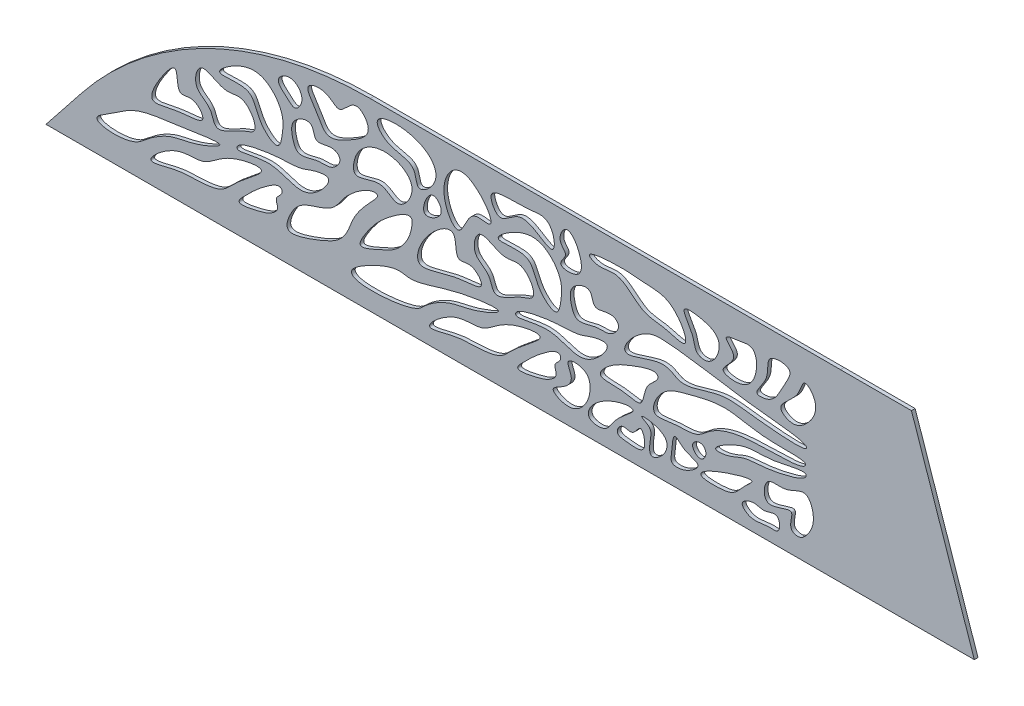
from build123d import *

# Parameters (mm, degrees)
SALIENTE_EXTRUIR1_DEPTH = 1


with BuildPart() as part:
    # Croquis2 → Saliente-Extruir1 (new body)
    with BuildSketch(Plane.XY):
        with BuildLine():
            Line((-140.923407086, 16.513809916), (-150.634750193, 4.281119486))
            Line((-150.634750193, 4.281119486), (81.974483808, 4.428260628))
            Line((81.974483808, 4.428260628), (101.237882269, 4.428260628))
            Line((101.237882269, 4.428260628), (84.179871787, 54.417480281))
            Line((84.179871787, 54.417480281), (64.916473326, 54.417480281))
            Line((64.916473326, 54.417480281), (-62.66668653, 54.336775265))
            ThreePointArc((-62.66668653, 54.336775265), (-106.11925474, 44.37219373), (-140.923407086, 16.513809916))
        make_face()
        with BuildLine():
            add(Edge.make_bspline(
                [(-92.205684954, 22.714796973), (-91.802560007, 21.763045235), (-98.804615112, 17.236326929), (-102.576737947, 12.23957137), (-109.402464372, 11.501499563), (-114.719362778, 11.744524185), (-125.825393726, 8.076123538), (-115.369854681, 17.42010162), (-107.474200982, 15.63632551), (-102.30806793, 21.870076839), (-92.605251322, 23.658147136), (-92.205684954, 22.714796973)],
                knots=[0, 0, 0, 0, 0.137666911, 0.216152979, 0.304696955, 0.407966614, 0.504225833, 0.632893463, 0.744250149, 0.863548342, 1, 1, 1, 1], degree=3))
        make_face(mode=Mode.SUBTRACT)
        with BuildLine():
            add(Edge.make_bspline(
                [(-86.575132814, 20.597298305), (-86.453176706, 19.69679669), (-89.367071096, 18.116368228), (-86.916603685, 16.0539287), (-89.862651004, 13.618513225), (-93.383907232, 12.534630146), (-100.071587714, 11.196574042), (-96.060944144, 15.052423007), (-92.78317285, 18.380734009), (-87.196303675, 22.305241626), (-86.595495362, 20.747651644), (-86.575132814, 20.597298305)],
                knots=[0, 0, 0, 0, 0.100037862, 0.223752743, 0.272835489, 0.361931863, 0.526926229, 0.683101427, 0.832970576, 0.983297058, 1, 1, 1, 1], degree=3))
        make_face(mode=Mode.SUBTRACT)
        with BuildLine():
            add(Edge.make_bspline(
                [(-27.875451607, 21.716419118), (-28.042422713, 21.083876098), (-35.12534219, 18.025053036), (-41.178852373, 17.621695169), (-47.389772208, 13.857790251), (-51.023345798, 9.288841508), (-76.678379325, 7.823413857), (-56.039840283, 18.687568859), (-51.166789821, 16.20059075), (-41.858487953, 20.802798425), (-27.643210348, 22.59622756), (-27.875451607, 21.716419118)],
                knots=[0, 0, 0, 0, 0.101306786, 0.208687695, 0.319856438, 0.369897245, 0.539759423, 0.585965852, 0.671453306, 0.859091694, 1, 1, 1, 1], degree=3))
        make_face(mode=Mode.SUBTRACT)
        with BuildLine():
            add(Edge.make_bspline(
                [(-16.609741445, 21.420728237), (-16.206616498, 20.468976499), (-23.208671604, 15.942258194), (-26.980794438, 10.945502634), (-33.806520863, 10.207430828), (-39.123419269, 10.450455449), (-50.229450217, 6.782054803), (-39.773911172, 16.126032885), (-31.878257474, 14.342256774), (-26.712124421, 20.576008103), (-17.009307813, 22.364078401), (-16.609741445, 21.420728237)],
                knots=[0, 0, 0, 0, 0.137666911, 0.216152979, 0.304696955, 0.407966614, 0.504225833, 0.632893463, 0.744250149, 0.863548342, 1, 1, 1, 1], degree=3))
        make_face(mode=Mode.SUBTRACT)
        with BuildLine():
            add(Edge.make_bspline(
                [(-103.471395116, 23.010487854), (-103.619901272, 22.446352179), (-110.695490352, 19.291825157), (-116.904148272, 18.901199105), (-122.596194499, 15.222899499), (-127.782380381, 10.368532406), (-140.636545521, 11.269519032), (-132.414774866, 15.857270722), (-126.152722763, 20.727532604), (-117.607238327, 21.261724361), (-103.264836882, 23.795148047), (-103.471395116, 23.010487854)],
                knots=[0, 0, 0, 0, 0.101306786, 0.208687695, 0.319856438, 0.369897245, 0.539759423, 0.585965852, 0.671453306, 0.859091694, 1, 1, 1, 1], degree=3))
        make_face(mode=Mode.SUBTRACT)
        with BuildLine():
            add(Edge.make_bspline(
                [(-60.73742357, 32.564353965), (-60.271937474, 31.593304482), (-66.076211875, 27.724556688), (-69.421439661, 17.825803591), (-73.680771059, 15.183714533), (-78.0102017, 13.515587852), (-86.67036516, 10.47225481), (-83.67595972, 18.408432631), (-80.577836796, 20.914590464), (-72.859550638, 22.732736455), (-68.574252013, 29.726559886), (-62.405794108, 33.536573592), (-60.804454521, 32.70418708), (-60.73742357, 32.564353965)],
                knots=[0, 0, 0, 0, 0.139538346, 0.165887445, 0.263490987, 0.357787779, 0.488799598, 0.565750137, 0.69720214, 0.788875945, 0.819155731, 0.979906192, 1, 1, 1, 1], degree=3))
        make_face(mode=Mode.SUBTRACT)
        with BuildLine():
            add(Edge.make_bspline(
                [(-98.758161385, 24.574610579), (-98.277956099, 23.630831376), (-87.811743674, 27.779195859), (-80.679689336, 19.962886758), (-71.966189082, 30.620756207), (-77.8972006, 29.960216513), (-81.651012757, 28.066728549), (-88.115487595, 28.353175745), (-98.709877292, 26.471512653), (-98.822584456, 24.701225499), (-98.758161385, 24.574610579)],
                knots=[0, 0, 0, 0, 0.173914473, 0.388452632, 0.503873436, 0.557098589, 0.647485373, 0.766680945, 0.976668095, 1, 1, 1, 1], degree=3))
        make_face(mode=Mode.SUBTRACT)
        with BuildLine():
            add(Edge.make_bspline(
                [(-51.329656744, 30.329113167), (-51.684364022, 27.088103468), (-54.454716076, 22.541795298), (-60.039369763, 20.094348809), (-67.090616873, 17.017062152), (-62.46106287, 24.396988676), (-58.822981991, 28.413339103), (-51.078469767, 33.712617249), (-51.296448609, 30.632540507), (-51.329656744, 30.329113167)],
                knots=[0, 0, 0, 0, 0.224720507, 0.375822377, 0.501740602, 0.617102565, 0.78961388, 0.978961388, 1, 1, 1, 1], degree=3))
        make_face(mode=Mode.SUBTRACT)
        with BuildLine():
            add(Edge.make_bspline(
                [(-32.477538359, 25.779047969), (-32.436786797, 24.296704773), (-41.089243269, 24.706077459), (-51.339051208, 19.257750479), (-48.554505392, 29.983166486), (-38.574241423, 37.641213819), (-39.89615189, 27.378304205), (-34.921286445, 29.653255806), (-32.50396138, 26.740188673), (-32.477538359, 25.779047969)],
                knots=[0, 0, 0, 0, 0.14020184, 0.385455427, 0.525796143, 0.730510289, 0.839207685, 0.909094132, 1, 1, 1, 1], degree=3))
        make_face(mode=Mode.SUBTRACT)
        with BuildLine():
            add(Edge.make_bspline(
                [(-3.033262147, 8.916712976), (-2.244692201, 8.203526295), (1.470040688, 7.835400725), (3.530798908, 12.102338745), (6.127780455, 14.114768646), (10.814473459, 18.155324741), (-0.509412981, 16.233538463), (-4.348285226, 10.106026553), (-3.033262147, 8.916712976)],
                knots=[0, 0, 0, 0, 0.13121694, 0.261967856, 0.433385636, 0.495907082, 0.781181993, 1, 1, 1, 1], degree=3))
        make_face(mode=Mode.SUBTRACT)
        with BuildLine():
            add(Edge.make_bspline(
                [(-10.979189305, 19.303229569), (-10.857233197, 18.402727954), (-13.771127587, 16.822299492), (-11.320660177, 14.759859964), (-14.266707495, 12.32444449), (-17.787963723, 11.24056141), (-24.475644205, 9.902505306), (-20.465000635, 13.758354272), (-17.187229342, 17.086665274), (-11.600360166, 21.011172891), (-10.999551854, 19.453582908), (-10.979189305, 19.303229569)],
                knots=[0, 0, 0, 0, 0.100037862, 0.223752743, 0.272835489, 0.361931863, 0.526926229, 0.683101427, 0.832970576, 0.983297058, 1, 1, 1, 1], degree=3))
        make_face(mode=Mode.SUBTRACT)
        with BuildLine():
            add(Edge.make_bspline(
                [(-13.020020123, 10.844042343), (-13.079741619, 10.067018611), (-8.925268124, 7.980384497), (-4.615199834, 10.361871707), (-2.640858856, 14.932384707), (-3.353597744, 20.208995054), (-10.496104983, 20.404822533), (-7.165671724, 15.74557424), (-9.692856103, 12.772498346), (-12.968673963, 11.512096368), (-13.020020123, 10.844042343)],
                knots=[0, 0, 0, 0, 0.115790929, 0.261605928, 0.423709519, 0.543191472, 0.682024284, 0.775824877, 0.900447576, 1, 1, 1, 1], degree=3))
        make_face(mode=Mode.SUBTRACT)
        with BuildLine():
            add(Edge.make_bspline(
                [(5.589406647, 11.457118018), (4.864473397, 11.147060302), (3.518627666, 8.767568714), (7.91915639, 8.388545505), (12.909094615, 7.716484892), (10.920139502, 15.515485139), (8.713691841, 10.317718328), (6.493094754, 11.843630115), (5.589406647, 11.457118018)],
                knots=[0, 0, 0, 0, 0.11702101, 0.265473491, 0.499789655, 0.707726475, 0.854123817, 1, 1, 1, 1], degree=3))
        make_face(mode=Mode.SUBTRACT)
        with BuildLine():
            add(Edge.make_bspline(
                [(11.068959568, 16.296260232), (11.345693545, 16.022397332), (14.108483371, 14.901540724), (13.108457293, 11.919706032), (12.994442149, 7.52081155), (17.528521559, 10.165795766), (19.258710949, 16.206665104), (10.349245704, 17.008507164), (11.068959568, 16.296260232)],
                knots=[0, 0, 0, 0, 0.100831532, 0.25515108, 0.381411636, 0.512576107, 0.737763133, 1, 1, 1, 1], degree=3))
        make_face(mode=Mode.SUBTRACT)
        with BuildLine():
            add(Edge.make_bspline(
                [(20.029504698, 16.296260232), (19.396010342, 16.196927939), (19.300073517, 12.808771346), (18.449298601, 8.960869803), (23.36795948, 9.302114629), (28.012613549, 13.316849909), (22.599537026, 13.70507933), (20.542918285, 16.376763788), (20.029504698, 16.296260232)],
                knots=[0, 0, 0, 0, 0.174988013, 0.298355592, 0.478987194, 0.673221019, 0.858181494, 1, 1, 1, 1], degree=3))
        make_face(mode=Mode.SUBTRACT)
        with BuildLine():
            add(Edge.make_bspline(
                [(29.24000352, 12.743992104), (25.975683225, 11.089660736), (26.09550318, 9.83401953), (33.75643826, 10.225014229), (36.673456582, 11.054678144), (38.337312262, 13.685479114), (43.159155366, 17.68986783), (33.442795047, 14.637836975), (30.031739731, 13.145237671), (29.24000352, 12.743992104)],
                knots=[0, 0, 0, 0, 0.381237911, 0.430835157, 0.495972459, 0.63184877, 0.681407126, 0.907533627, 1, 1, 1, 1], degree=3))
        make_face(mode=Mode.SUBTRACT)
        with BuildLine():
            add(Edge.make_bspline(
                [(24.824599415, 16.833368405), (24.607789074, 15.798700476), (26.848267052, 13.414357491), (28.899100312, 16.204061152), (27.486935928, 18.898146726), (25.020559407, 17.768533754), (24.824599415, 16.833368405)],
                knots=[0, 0, 0, 0, 0.304007816, 0.526233533, 0.725228194, 1, 1, 1, 1], degree=3))
        make_face(mode=Mode.SUBTRACT)
        with BuildLine():
            add(Edge.make_bspline(
                [(47.738883242, 11.340551354), (48.62260712, 10.685832918), (48.713093751, 7.472736449), (44.227586396, 8.08967099), (40.993801578, 6.374792092), (37.257188326, 10.015279646), (41.456913555, 11.994955727), (44.190662415, 10.304045855), (46.943426943, 11.929875597), (47.738883242, 11.340551354)],
                knots=[0, 0, 0, 0, 0.160267158, 0.21076581, 0.504986522, 0.580130515, 0.727204348, 0.85574055, 1, 1, 1, 1], degree=3))
        make_face(mode=Mode.SUBTRACT)
        with BuildLine():
            add(Edge.make_bspline(
                [(45.054720682, 18.081996856), (46.06927865, 19.190478678), (50.34468551, 17.737364414), (55.852853916, 22.53607311), (58.251146001, 15.543939157), (56.605204987, 11.765461856), (54.086303424, 8.999676875), (50.449404652, 10.195663467), (53.688210171, 17.037464328), (43.649269803, 10.259098879), (44.058719335, 16.993789556), (45.054720682, 18.081996856)],
                knots=[0, 0, 0, 0, 0.115773361, 0.264232273, 0.386481489, 0.502340138, 0.579489949, 0.628580772, 0.723680545, 0.886344174, 1, 1, 1, 1], degree=3))
        make_face(mode=Mode.SUBTRACT)
        with BuildLine():
            add(Edge.make_bspline(
                [(-23.162217877, 23.280541843), (-22.68201259, 22.33676264), (-12.215800165, 26.485127123), (-5.083745828, 18.668818023), (3.629754427, 29.326687471), (-2.301257091, 28.666147777), (-6.055069248, 26.772659814), (-12.519544086, 27.059107009), (-23.113933783, 25.177443917), (-23.226640947, 23.407156764), (-23.162217877, 23.280541843)],
                knots=[0, 0, 0, 0, 0.173914473, 0.388452632, 0.503873436, 0.557098589, 0.647485373, 0.766680945, 0.976668095, 1, 1, 1, 1], degree=3))
        make_face(mode=Mode.SUBTRACT)
        with BuildLine():
            add(Edge.make_bspline(
                [(15.381956031, 27.714692848), (15.253882238, 26.713156926), (11.358376869, 24.683201722), (11.696956364, 19.060483861), (8.464003922, 19.248459826), (4.856118523, 20.204669131), (-2.257724891, 19.489916631), (2.256785883, 24.388350028), (7.049215017, 26.680027692), (15.167352982, 29.580336225), (15.403340027, 27.881915502), (15.381956031, 27.714692848)],
                knots=[0, 0, 0, 0, 0.100037862, 0.223752743, 0.272835489, 0.361931863, 0.526926229, 0.683101427, 0.832970576, 0.983297058, 1, 1, 1, 1], degree=3))
        make_face(mode=Mode.SUBTRACT)
        with BuildLine():
            add(Edge.make_bspline(
                [(55.488285601, 27.436087963), (55.30394795, 28.433925607), (42.760617862, 27.52349654), (34.27751659, 30.758631897), (24.11490803, 28.112824625), (15.861942033, 26.002779475), (12.735310907, 17.684288379), (20.543013488, 19.522878334), (25.75479227, 18.798442261), (30.066503999, 23.125621961), (39.12867169, 26.619479492), (54.241877688, 25.199437951), (55.519153324, 27.268997975), (55.488285601, 27.436087963)],
                knots=[0, 0, 0, 0, 0.114550047, 0.246019978, 0.351313901, 0.440260507, 0.519920021, 0.570512894, 0.6558102, 0.704961009, 0.808183564, 0.980818356, 1, 1, 1, 1], degree=3))
        make_face(mode=Mode.SUBTRACT)
        with BuildLine():
            add(Edge.make_bspline(
                [(55.571158094, 25.062930246), (55.054545663, 25.987282937), (44.178039045, 22.629287652), (39.35475209, 24.787397273), (28.873846675, 18.30981476), (34.988684692, 18.759787933), (38.58860678, 20.957324311), (45.108017123, 20.822637604), (55.550092321, 23.261880754), (55.640465451, 24.938921535), (55.571158094, 25.062930246)],
                knots=[0, 0, 0, 0, 0.173914473, 0.388452632, 0.503873436, 0.557098589, 0.647485373, 0.766680945, 0.976668095, 1, 1, 1, 1], degree=3))
        make_face(mode=Mode.SUBTRACT)
        with BuildLine():
            add(Edge.make_bspline(
                [(-108.073481868, 27.073116705), (-108.041265106, 25.569592773), (-115.011431825, 25.865998801), (-123.856158818, 22.466065593), (-120.195936147, 30.313584003), (-114.453306123, 37.590138326), (-115.494295858, 28.517152828), (-110.518238625, 30.990858991), (-108.094370986, 28.047990845), (-108.073481868, 27.073116705)],
                knots=[0, 0, 0, 0, 0.16554106, 0.363113048, 0.54333429, 0.681804372, 0.810147069, 0.892664364, 1, 1, 1, 1], degree=3))
        make_face(mode=Mode.SUBTRACT)
        with BuildLine():
            add(Edge.make_bspline(
                [(-109.776725626, 33.714538143), (-109.103916475, 32.062460714), (-105.83207503, 31.203315351), (-104.745362123, 24.457077502), (-98.83128897, 29.39842089), (-92.206027167, 30.710204303), (-96.620153924, 38.328213681), (-102.598608626, 35.350248088), (-109.056212015, 41.337207318), (-110.399214891, 35.2430555), (-109.776725626, 33.714538143)],
                knots=[0, 0, 0, 0, 0.122947635, 0.197230717, 0.379613325, 0.462451253, 0.61342153, 0.720954251, 0.886247708, 1, 1, 1, 1], degree=3))
        make_face(mode=Mode.SUBTRACT)
        with BuildLine():
            add(Edge.make_bspline(
                [(-103.471395116, 40.06414663), (-102.922868116, 39.345851186), (-94.044466633, 41.43345587), (-93.815432944, 34.147991751), (-87.369341096, 28.986697114), (-86.39264908, 34.561309264), (-86.006961443, 39.198135198), (-90.398993123, 45.011314598), (-97.179996163, 45.713177477), (-104.03971449, 40.808360162), (-103.471395116, 40.06414663)],
                knots=[0, 0, 0, 0, 0.150869226, 0.29454511, 0.406379079, 0.468936505, 0.566427014, 0.712110948, 0.843686995, 1, 1, 1, 1], degree=3))
        make_face(mode=Mode.SUBTRACT)
        with BuildLine():
            add(Edge.make_bspline(
                [(-34.180782118, 32.420469407), (-33.507972967, 30.768391979), (-30.236131522, 29.909246615), (-29.149418615, 23.163008766), (-23.235345461, 28.104352154), (-16.610083659, 29.416135568), (-21.024210416, 37.034144946), (-27.002665117, 34.056179352), (-33.460268506, 40.043138582), (-34.803271383, 33.948986764), (-34.180782118, 32.420469407)],
                knots=[0, 0, 0, 0, 0.122947635, 0.197230717, 0.379613325, 0.462451253, 0.61342153, 0.720954251, 0.886247708, 1, 1, 1, 1], degree=3))
        make_face(mode=Mode.SUBTRACT)
        with BuildLine():
            add(Edge.make_bspline(
                [(-83.199355761, 38.836812684), (-84.170283329, 37.670045282), (-84.030375686, 35.181011402), (-82.377033768, 30.409363197), (-77.229863483, 33.149625464), (-73.021490047, 32.116380807), (-69.982124829, 35.742723936), (-73.216723178, 38.462577552), (-77.87023712, 35.48221866), (-78.079098906, 41.72241535), (-82.088498364, 40.171734302), (-83.199355761, 38.836812684)],
                knots=[0, 0, 0, 0, 0.118785798, 0.20372498, 0.369297926, 0.472854545, 0.583848702, 0.633218082, 0.781041846, 0.864094823, 1, 1, 1, 1], degree=3))
        make_face(mode=Mode.SUBTRACT)
        with BuildLine():
            add(Edge.make_bspline(
                [(-66.586453789, 38.836812684), (-67.222535469, 37.306332509), (-67.89082393, 32.076313413), (-59.841552865, 37.55515985), (-54.893378171, 31.182575162), (-49.387842715, 39.115434549), (-56.857883142, 45.443217149), (-64.702440628, 43.36994873), (-66.586453789, 38.836812684)],
                knots=[0, 0, 0, 0, 0.101141447, 0.28046914, 0.396201309, 0.560751813, 0.700428697, 1, 1, 1, 1], degree=3))
        make_face(mode=Mode.SUBTRACT)
        with BuildLine():
            add(Edge.make_bspline(
                [(-47.87195203, 37.35315559), (-47.375731904, 38.834505454), (-45.552690706, 41.492142324), (-41.547391927, 36.321494257), (-48.600010912, 33.050936588), (-48.224400719, 36.301001939), (-47.87195203, 37.35315559)],
                knots=[0, 0, 0, 0, 0.24865073, 0.481622394, 0.823391638, 1, 1, 1, 1], degree=3))
        make_face(mode=Mode.SUBTRACT)
        with BuildLine():
            add(Edge.make_bspline(
                [(-87.566498355, 46.385773526), (-87.813009041, 45.274050288), (-85.555717254, 43.595440663), (-83.021561008, 41.06034201), (-80.530072842, 44.42138596), (-81.970001714, 47.670090828), (-85.187093106, 48.853875471), (-87.380646042, 47.223937333), (-87.566498355, 46.385773526)],
                knots=[0, 0, 0, 0, 0.218720128, 0.339791489, 0.498378835, 0.685975107, 0.83509988, 1, 1, 1, 1], degree=3))
        make_face(mode=Mode.SUBTRACT)
        with BuildLine():
            add(Edge.make_bspline(
                [(-79.479460945, 48.7142402), (-80.008377433, 47.63555805), (-77.001116385, 44.122950565), (-74.703573543, 38.371126383), (-67.809674107, 41.932745381), (-61.065412917, 46.106433193), (-67.058351553, 52.927844534), (-70.761719622, 45.754553623), (-74.359845914, 50.529509468), (-78.936737861, 49.82107978), (-79.479460945, 48.7142402)],
                knots=[0, 0, 0, 0, 0.116134081, 0.234719327, 0.387508115, 0.559608153, 0.66669632, 0.795438918, 0.880834407, 1, 1, 1, 1], degree=3))
        make_face(mode=Mode.SUBTRACT)
        with BuildLine():
            add(Edge.make_bspline(
                [(-42.636896587, 41.89482139), (-42.322641621, 38.423145799), (-37.98064402, 31.442174809), (-36.140595503, 42.389350621), (-26.399632488, 39.038676716), (-37.608319281, 54.738365525), (-43.019820846, 46.125108727), (-42.636896587, 41.89482139)],
                knots=[0, 0, 0, 0, 0.1985725, 0.381466523, 0.477585842, 0.758036513, 1, 1, 1, 1], degree=3))
        make_face(mode=Mode.SUBTRACT)
        with BuildLine():
            add(Edge.make_bspline(
                [(-60.73742357, 49.411543737), (-60.544662358, 48.417716552), (-56.990233275, 44.639081597), (-50.374853842, 45.85413483), (-50.103758986, 38.073608254), (-42.414802891, 44.445987791), (-48.862162473, 52.97712714), (-61.25919074, 52.101640943), (-60.73742357, 49.411543737)],
                knots=[0, 0, 0, 0, 0.102406098, 0.299110243, 0.378625468, 0.507829762, 0.722806579, 1, 1, 1, 1], degree=3))
        make_face(mode=Mode.SUBTRACT)
        with BuildLine():
            add(Edge.make_bspline(
                [(-7.603412252, 37.542743949), (-8.57433982, 36.375976546), (-8.434432177, 33.886942667), (-6.781090259, 29.115294461), (-1.633919974, 31.855556729), (2.574453462, 30.822312071), (5.61381868, 34.4486552), (2.379220331, 37.168508816), (-2.274293611, 34.188149924), (-2.483155397, 40.428346614), (-6.492554855, 38.877665566), (-7.603412252, 37.542743949)],
                knots=[0, 0, 0, 0, 0.118785798, 0.20372498, 0.369297926, 0.472854545, 0.583848702, 0.633218082, 0.781041846, 0.864094823, 1, 1, 1, 1], degree=3))
        make_face(mode=Mode.SUBTRACT)
        with BuildLine():
            add(Edge.make_bspline(
                [(55.330594504, 31.951770156), (53.753942259, 32.892358649), (38.259279371, 33.897354101), (23.619571951, 37.126650261), (10.47543016, 37.628852817), (1.919935836, 25.995389595), (17.745708547, 33.25357759), (21.186602511, 27.864955136), (32.164799048, 33.227691472), (40.30951101, 31.511181344), (57.011995933, 30.201433415), (55.576378826, 31.805141813), (55.330594504, 31.951770156)],
                knots=[0, 0, 0, 0, 0.099677328, 0.267067778, 0.297767809, 0.406677629, 0.47274056, 0.561818037, 0.712100252, 0.844613011, 0.984461301, 1, 1, 1, 1], degree=3))
        make_face(mode=Mode.SUBTRACT)
        with BuildLine():
            add(Edge.make_bspline(
                [(-27.875451607, 38.770077894), (-27.326924607, 38.051782451), (-18.448523125, 40.139387135), (-18.219489435, 32.853923016), (-11.773397587, 27.692628378), (-10.796705572, 33.267240528), (-10.411017935, 37.904066462), (-14.803049614, 43.717245862), (-21.584052654, 44.419108742), (-28.443770981, 39.514291427), (-27.875451607, 38.770077894)],
                knots=[0, 0, 0, 0, 0.150869226, 0.29454511, 0.406379079, 0.468936505, 0.566427014, 0.712110948, 0.843686995, 1, 1, 1, 1], degree=3))
        make_face(mode=Mode.SUBTRACT)
        with BuildLine():
            add(Edge.make_bspline(
                [(48.901820289, 36.79519151), (47.815314018, 38.509698209), (53.710954161, 41.007663891), (54.73582542, 47.711904561), (59.737426124, 42.844096735), (56.693691564, 37.249012986), (52.102443188, 34.588323926), (49.329797514, 36.119843527), (48.901820289, 36.79519151)],
                knots=[0, 0, 0, 0, 0.267800279, 0.390798431, 0.490723643, 0.760932173, 0.894512878, 1, 1, 1, 1], degree=3))
        make_face(mode=Mode.SUBTRACT)
        with BuildLine():
            add(Edge.make_bspline(
                [(-29.802585568, 46.972842654), (-29.55567134, 45.959950477), (-27.156428287, 41.790841066), (-21.417183367, 50.860753193), (-11.154552652, 38.680944887), (-13.227115494, 50.705363197), (-23.553154117, 49.090514995), (-30.673341877, 50.544861404), (-29.802585568, 46.972842654)],
                knots=[0, 0, 0, 0, 0.085286671, 0.253990522, 0.484166523, 0.647648619, 0.699231967, 1, 1, 1, 1], degree=3))
        make_face(mode=Mode.SUBTRACT)
        with BuildLine():
            add(Edge.make_bspline(
                [(-10.979189305, 46.328041782), (-11.539908087, 47.649864932), (-9.362094939, 52.60162348), (-5.010184746, 45.924459106), (-5.270658131, 40.031760119), (-12.842115939, 40.590791935), (-8.586164818, 44.211918431), (-10.624155118, 45.49109388), (-10.979189305, 46.328041782)],
                knots=[0, 0, 0, 0, 0.162087623, 0.409403319, 0.604230089, 0.77400643, 0.897369859, 1, 1, 1, 1], degree=3))
        make_face(mode=Mode.SUBTRACT)
        with BuildLine():
            add(Edge.make_bspline(
                [(-2.926589796, 46.827177569), (-2.710032306, 46.653292066), (-0.342680309, 45.375704857), (5.318644037, 47.943171987), (10.593661882, 40.478171265), (16.837350415, 40.832545137), (25.252486804, 37.459881273), (19.738655417, 48.168218872), (11.672093455, 47.97999359), (6.579706689, 49.071517615), (-4.466713729, 48.063824824), (-2.926589796, 46.827177569)],
                knots=[0, 0, 0, 0, 0.018173889, 0.122894497, 0.279653893, 0.384629408, 0.472626168, 0.608786908, 0.726153064, 0.870750066, 1, 1, 1, 1], degree=3))
        make_face(mode=Mode.SUBTRACT)
        with BuildLine():
            add(Edge.make_bspline(
                [(22.580112723, 47.450285128), (22.014138538, 46.594076013), (25.370804443, 42.895953704), (25.321887293, 38.69252172), (30.36624504, 37.50233275), (33.749183526, 45.08648144), (28.010643168, 47.629839861), (23.059263873, 48.175147836), (22.580112723, 47.450285128)],
                knots=[0, 0, 0, 0, 0.195722298, 0.325152471, 0.402012975, 0.648328218, 0.8343024, 1, 1, 1, 1], degree=3))
        make_face(mode=Mode.SUBTRACT)
        with BuildLine():
            add(Edge.make_bspline(
                [(33.915974563, 46.430063904), (33.790437502, 45.751685767), (38.634765774, 42.651752872), (30.770164855, 38.318905338), (37.488048274, 36.767821361), (42.428927415, 39.383991109), (42.585923764, 48.602442841), (37.534132738, 47.419701632), (34.020981048, 46.997498759), (33.915974563, 46.430063904)],
                knots=[0, 0, 0, 0, 0.113933947, 0.288077368, 0.377523831, 0.561215078, 0.781648315, 0.904699033, 1, 1, 1, 1], degree=3))
        make_face(mode=Mode.SUBTRACT)
        with BuildLine():
            add(Edge.make_bspline(
                [(46.053840499, 47.608123033), (44.704892768, 46.623087639), (46.423947515, 42.392268588), (40.593374681, 37.088899284), (47.066414183, 37.37449557), (48.587653245, 41.726103331), (52.88530981, 48.397979362), (47.264997608, 48.492540266), (46.053840499, 47.608123033)],
                knots=[0, 0, 0, 0, 0.18416172, 0.363281009, 0.422910842, 0.690341932, 0.834649801, 1, 1, 1, 1], degree=3))
        make_face(mode=Mode.SUBTRACT)
    extrude(amount=SALIENTE_EXTRUIR1_DEPTH)


solid = part.part
